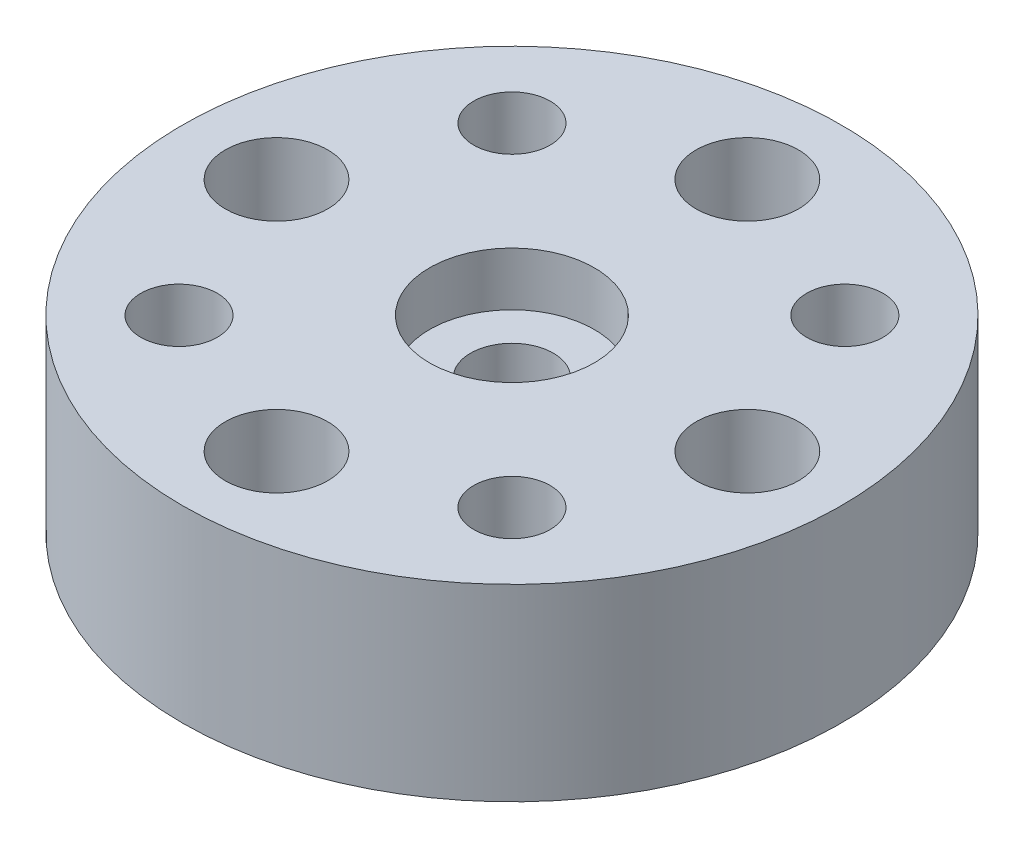
from build123d import *

# Parameters (mm, degrees)
SKETCH1_R                                        = 11.1125
EXTRUDE1_DEPTH                                   = 6.35
D_GAGEMENT_51_D                                  = 3.4544
TROU_POUR_TARAUDAGE_POUR_TROU_TARAUD_5_D         = 2.5781
CHAMBRAGE_POUR_VIS_T_TE_RONDE_BOMB_E_D           = 2.794
CHAMBRAGE_POUR_VIS_T_TE_RONDE_BOMB_E_CBORE_D     = 5.55752
CHAMBRAGE_POUR_VIS_T_TE_RONDE_BOMB_E_CBORE_DEPTH = 1.8034


with BuildPart() as part:
    # Sketch1 → Extrude1 (new body)
    with BuildSketch(Plane(origin=(0, 0, 0), x_dir=(1, 0, 0), z_dir=(0, 1, 0))):
        Circle(SKETCH1_R)
    extrude(amount=-EXTRUDE1_DEPTH)

    # Dégagement #51 (through all)
    with Locations(Plane(origin=(0, 0, 0), x_dir=(-1, 0, 0), z_dir=(0, 1, 0))):
        with Locations((7.9375, 0), (0, -7.9375), (-7.9375, 0), (0, 7.9375)):
            Hole(D_GAGEMENT_51_D / 2)

    # Trou pour taraudage pour trou taraudé #5-401 (through all)
    with Locations(Plane.XZ.offset(6.35)):
        with Locations((-5.612660076, -5.612660076), (5.612660076, -5.612660076), (5.612660076, 5.612660076), (-5.612660076, 5.612660076)):
            Hole(TROU_POUR_TARAUDAGE_POUR_TROU_TARAUD_5_D / 2)

    # Chambrage pour vis à tête ronde bombée #31 (through all)
    with Locations(Plane(origin=(0, 0, 0), x_dir=(-1, 0, 0), z_dir=(0, 1, 0))):
        with Locations((0, 0)):
            CounterBoreHole(CHAMBRAGE_POUR_VIS_T_TE_RONDE_BOMB_E_D / 2, CHAMBRAGE_POUR_VIS_T_TE_RONDE_BOMB_E_CBORE_D / 2, CHAMBRAGE_POUR_VIS_T_TE_RONDE_BOMB_E_CBORE_DEPTH)


solid = part.part
